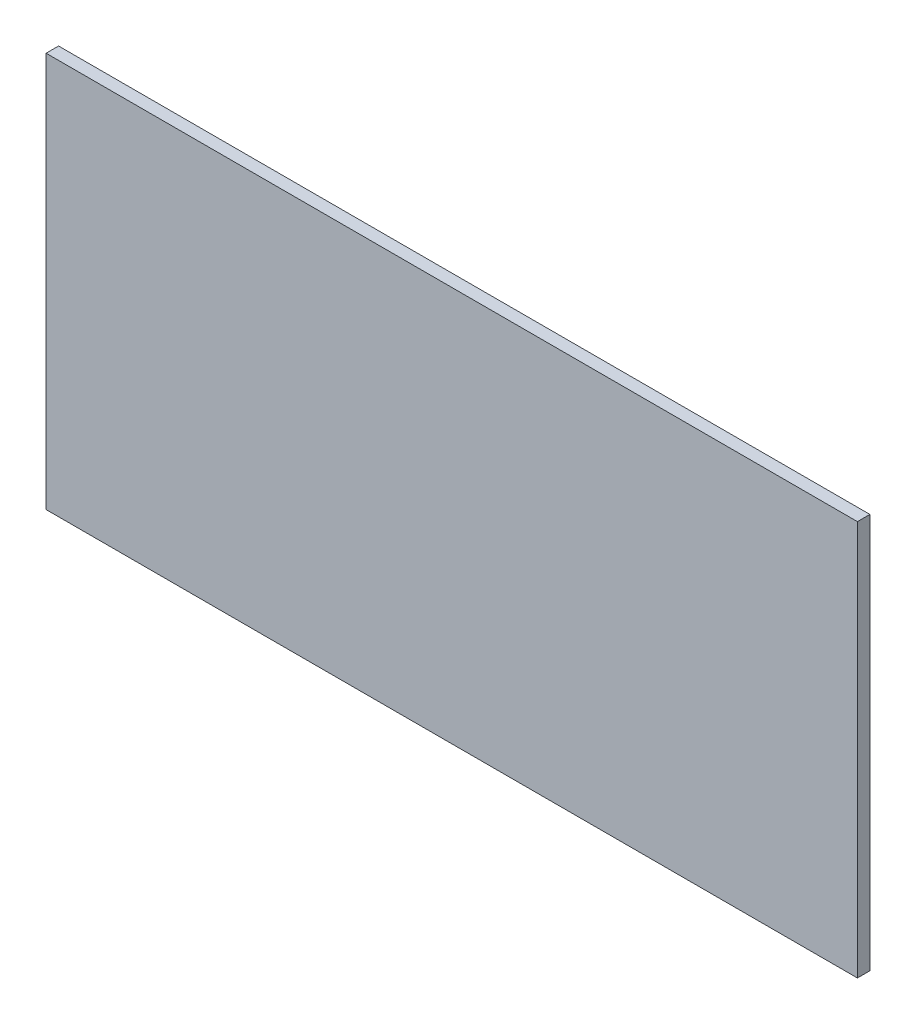
from build123d import *

# Parameters (mm, degrees)
ESQUISSE1_W        = 195
ESQUISSE1_H        = 95
BOSS_EXTRU_1_DEPTH = 3


with BuildPart() as part:
    # Esquisse1 → Boss.-Extru.1 (new body)
    with BuildSketch(Plane.XY):
        with Locations((97.5, 47.5)):
            Rectangle(ESQUISSE1_W, ESQUISSE1_H)
    extrude(amount=BOSS_EXTRU_1_DEPTH)


solid = part.part
